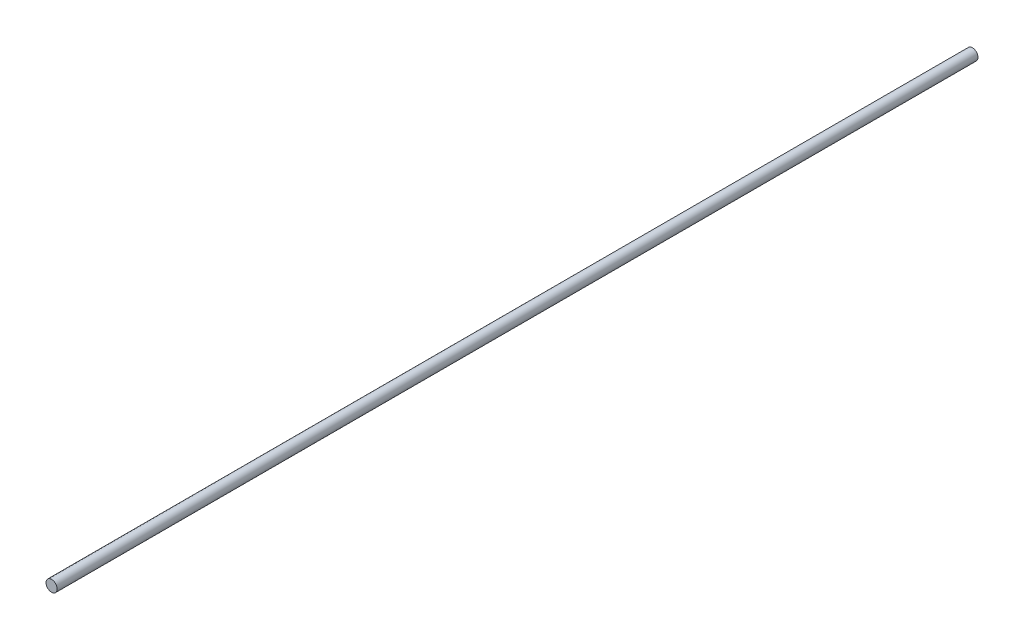
from build123d import *

# Parameters (mm, degrees)
SKETCH1_R           = 4
BOSS_EXTRUDE1_DEPTH = 660


with BuildPart() as part:
    # Sketch1 → Boss-Extrude1 (new body)
    with BuildSketch(Plane.XY):
        Circle(SKETCH1_R)
    extrude(amount=BOSS_EXTRUDE1_DEPTH)


solid = part.part
